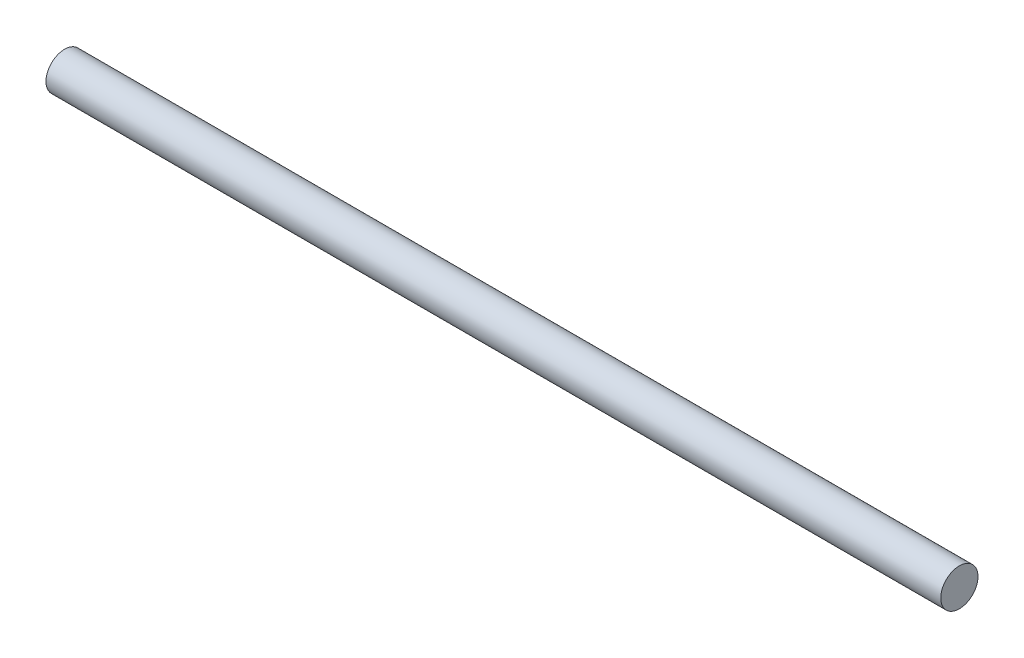
from build123d import *

# Parameters (mm, degrees)
SKETCH1_R           = 3.175
BOSS_EXTRUDE1_DEPTH = 152.4


with BuildPart() as part:
    # Sketch1 → Boss-Extrude1 (new body)
    with BuildSketch(Plane(origin=(0, 0, 0), x_dir=(0, 0, -1), z_dir=(1, 0, 0))):
        Circle(SKETCH1_R)
    extrude(amount=BOSS_EXTRUDE1_DEPTH)


solid = part.part
